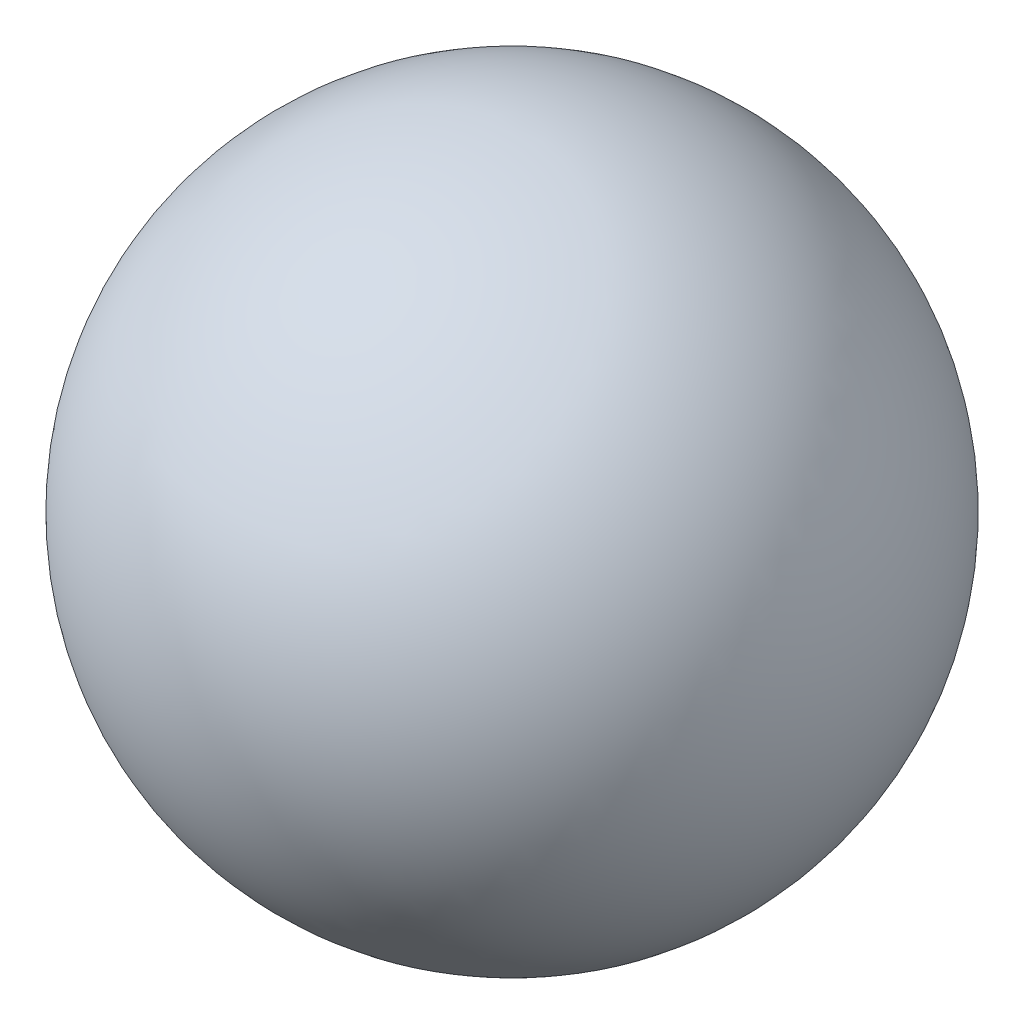
from build123d import *


with BuildPart() as part:
    # Schizzo1 → Rivoluzione2 (revolve)
    with BuildSketch(Plane.XY):
        with BuildLine():
            Line((0, 75), (0, -75))
            ThreePointArc((0, -75), (-75, 0), (0, 75))
        make_face()
    revolve(axis=Axis((0, 75, 0), (0, -1, 0)))


solid = part.part
